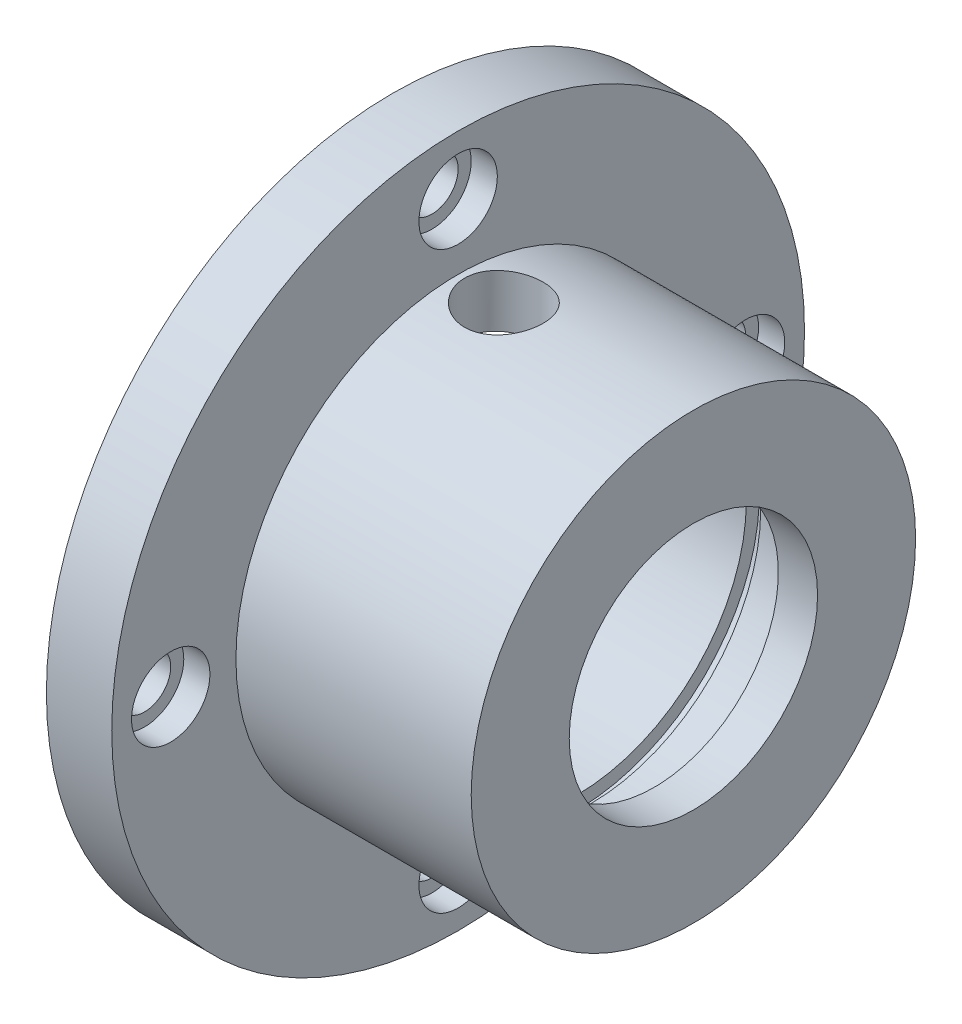
from build123d import *

# Parameters (mm, degrees)
SKETCH1_R           = 26.5
SKETCH1_R_2         = 2
BOSS_EXTRUDE1_DEPTH = 11.5
CUT_EXTRUDE1_START  = -18
SKETCH2_R           = 26.5
SKETCH2_R_2         = 2
SKETCH2_R_3         = 17
CUT_EXTRUDE1_DEPTH  = 18
SKETCH3_R           = 13
CUT_EXTRUDE2_DEPTH  = 20
SKETCH4_R           = 9.5
CUT_EXTRUDE3_DEPTH  = 20
SKETCH5_R           = 14
CUT_EXTRUDE4_DEPTH  = 0.55
SKETCH6_R           = 3
CUT_EXTRUDE5_DEPTH  = 33
SKETCH9_R           = 3
CUT_EXTRUDE7_DEPTH  = 2


with BuildPart() as part:
    # Sketch1 → Boss-Extrude1 (new, symmetric)
    with BuildSketch(Plane(origin=(0, 0, 0), x_dir=(0, 0, -1), z_dir=(1, 0, 0))):
        Circle(SKETCH1_R)
        with Locations((0, -21.987670406)):
            Circle(SKETCH1_R_2, mode=Mode.SUBTRACT)
        with Locations((-21.987670406, 0)):
            Circle(SKETCH1_R_2, mode=Mode.SUBTRACT)
        with Locations((0, 21.987670406)):
            Circle(SKETCH1_R_2, mode=Mode.SUBTRACT)
        with Locations((21.987670406, 0)):
            Circle(SKETCH1_R_2, mode=Mode.SUBTRACT)
    extrude(amount=BOSS_EXTRUDE1_DEPTH, both=True)

    # Sketch2 → Cut-Extrude1 (cut)
    with BuildSketch(Plane(origin=(11.5, 0, 0), x_dir=(0, 0, -1), z_dir=(1, 0, 0)).offset(CUT_EXTRUDE1_START)):
        Circle(SKETCH2_R)
        with Locations((0, -21.987670406)):
            Circle(SKETCH2_R_2, mode=Mode.SUBTRACT)
        with Locations((-21.987670406, 0)):
            Circle(SKETCH2_R_2, mode=Mode.SUBTRACT)
        with Locations((0, 21.987670406)):
            Circle(SKETCH2_R_2, mode=Mode.SUBTRACT)
        Circle(SKETCH2_R_3, mode=Mode.SUBTRACT)
        with Locations((21.987670406, 0)):
            Circle(SKETCH2_R_2, mode=Mode.SUBTRACT)
    extrude(amount=CUT_EXTRUDE1_DEPTH, mode=Mode.SUBTRACT)

    # Sketch3 → Cut-Extrude2 (cut)
    with BuildSketch(Plane.ZY.offset(11.5)):
        Circle(SKETCH3_R)
    extrude(amount=-CUT_EXTRUDE2_DEPTH, mode=Mode.SUBTRACT)

    # Sketch4 → Cut-Extrude3 (cut)
    with BuildSketch(Plane.ZY.offset(-8.5)):
        Circle(SKETCH4_R)
    extrude(amount=-CUT_EXTRUDE3_DEPTH, mode=Mode.SUBTRACT)

    # Sketch5 → Cut-Extrude4 (cut, symmetric)
    with BuildSketch(Plane.ZY.offset(-3.1)):
        Circle(SKETCH5_R)
    extrude(amount=CUT_EXTRUDE4_DEPTH, both=True, mode=Mode.SUBTRACT)

    # Sketch6 → Cut-Extrude5 (cut)
    with BuildSketch(Plane(origin=(0, 0, 0), x_dir=(1, 0, 0), z_dir=(0, 1, 0))):
        with Locations((-3, 0)):
            Circle(SKETCH6_R)
    extrude(amount=CUT_EXTRUDE5_DEPTH, mode=Mode.SUBTRACT)

    # Sketch9 → Cut-Extrude7 (cut)
    with BuildSketch(Plane(origin=(-6.5, 0, 0), x_dir=(0, 0, -1), z_dir=(1, 0, 0))):
        with Locations((0, 21.987670406)):
            Circle(SKETCH9_R)
        with Locations((21.987670406, 0)):
            Circle(SKETCH9_R)
        with Locations((0, -21.987670406)):
            Circle(SKETCH9_R)
        with Locations((-21.987670406, 0)):
            Circle(SKETCH9_R)
    extrude(amount=-CUT_EXTRUDE7_DEPTH, mode=Mode.SUBTRACT)


solid = part.part
